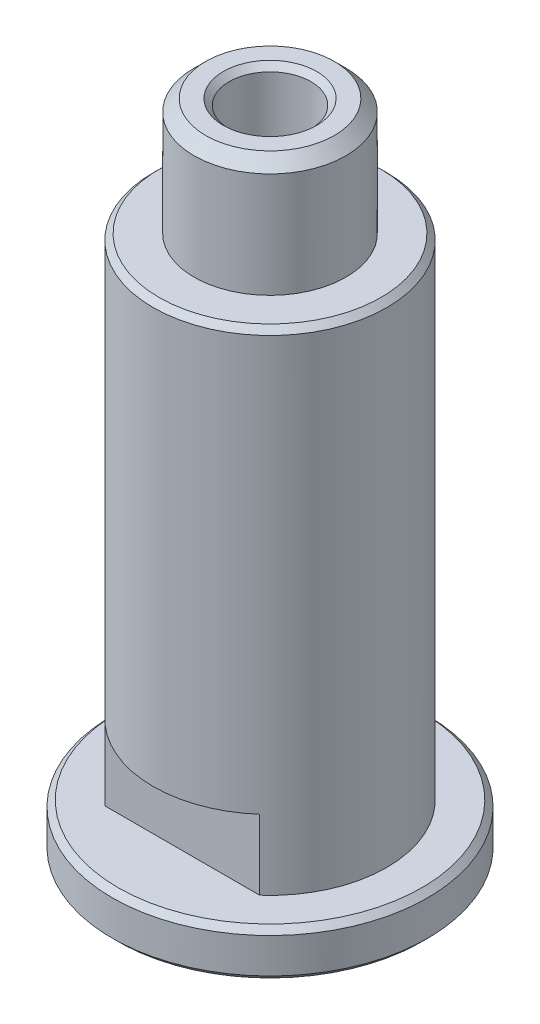
from build123d import *

# Parameters (mm, degrees)
CHAMFER1_SIZE       = 1
CHAMFER2_SIZE       = 0.5
SKETCH2_OUTSIDE_W   = 43.394
SKETCH2_OUTSIDE_H   = 43.394
SKETCH2_OUTSIDE_W_2 = 33.661520222
SKETCH2_OUTSIDE_H_2 = 15
CUT_EXTRUDE1_DEPTH  = 6


with BuildPart() as part:
    # Sketch1 → Revolve1 (revolve)
    with BuildSketch(Plane.XY):
        Polygon((3.5, -5), (3.5, 56), (6.5, 56), (6.5, 46), (10, 46), (10, 4), (13.5, 4), (13.5, 0), (6.25, 0), (6.25, -5), align=None)
    revolve(axis=Axis((0, 0, 0), (0, 1, 0)))

    # Chamfer1
    chamfer1_edges = [part.edges().sort_by_distance(p)[0] for p in [
        (-6.5, 56, 0),
    ]]
    chamfer(chamfer1_edges, length=CHAMFER1_SIZE)

    # Chamfer2
    chamfer2_edges = [part.edges().sort_by_distance(p)[0] for p in [
        (-10, 46, 0),
        (-3.5, 56, 0),
        (-3.5, -5, 0),
        (-6.25, -5, 0),
        (-13.5, 0, 0),
        (-13.5, 4, 0),
    ]]
    chamfer(chamfer2_edges, length=CHAMFER2_SIZE)

    # Sketch2 outside → Cut-Extrude1 (cut)
    with BuildSketch(Plane(origin=(0, 4, 0), x_dir=(1, 0, 0), z_dir=(0, 1, 0))):
        Rectangle(SKETCH2_OUTSIDE_W, SKETCH2_OUTSIDE_H)
        Rectangle(SKETCH2_OUTSIDE_W_2, SKETCH2_OUTSIDE_H_2, mode=Mode.SUBTRACT)
    extrude(amount=CUT_EXTRUDE1_DEPTH, mode=Mode.SUBTRACT)


solid = part.part
